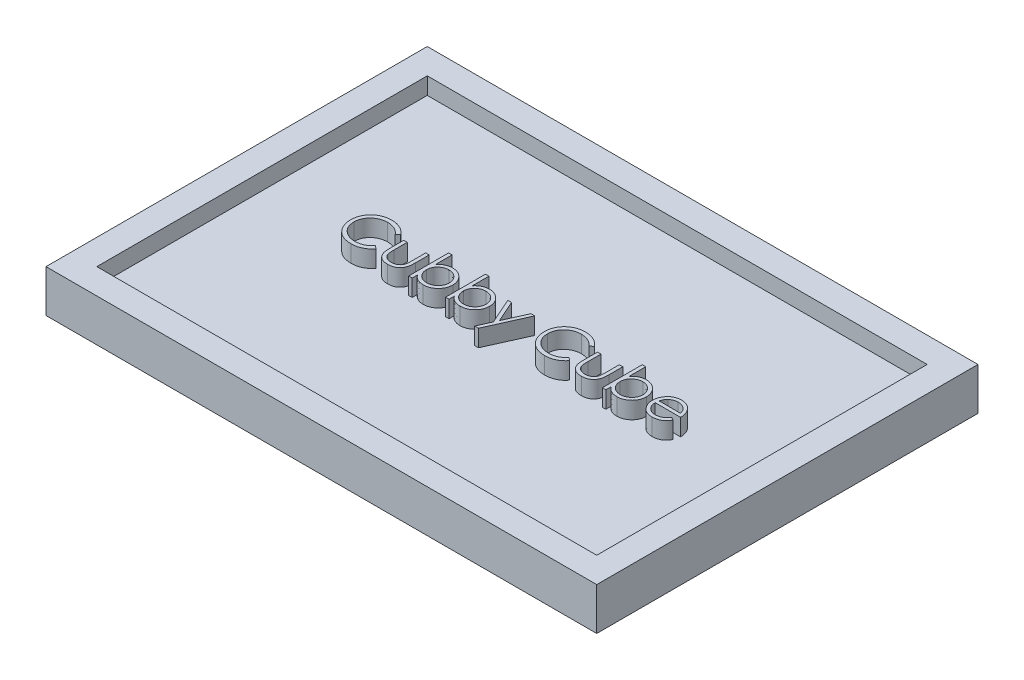
from build123d import *

# Parameters (mm, degrees)
SKETCH1_W           = 82.55
SKETCH1_H           = 57.15
BOSS_EXTRUDE1_DEPTH = 6.35
SHELL1_T            = -3.81
BOSS_EXTRUDE2_DEPTH = 2.54


with BuildPart() as part:
    # Sketch1 → Boss-Extrude1 (new body)
    with BuildSketch(Plane(origin=(0, 0, 0), x_dir=(1, 0, 0), z_dir=(0, 1, 0))):
        with Locations((41.275, 28.575)):
            Rectangle(SKETCH1_W, SKETCH1_H)
    extrude(amount=BOSS_EXTRUDE1_DEPTH)

    # Shell1
    shell1_openings = [part.faces().sort_by_distance(p)[0] for p in [
        (41.275, 6.35, -28.575),
    ]]
    offset(amount=SHELL1_T, openings=shell1_openings, kind=Kind.INTERSECTION)

    # Sketch2 → Boss-Extrude2 (add)
    with BuildSketch(Plane(origin=(0, 3.81, 0), x_dir=(1, 0, 0), z_dir=(0, 1, 0))):
        with BuildLine():
            Line((22.421777935, 30.73376706), (21.964693267, 30.383957364))
            add(Edge.make_bspline(
                [(21.964693267, 30.383957364), (21.932086807, 30.422817197), (21.867313494, 30.500012949), (21.763105272, 30.608412739), (21.654502421, 30.709970084), (21.541546454, 30.805168782), (21.422204204, 30.89067976), (21.299366661, 30.970959201), (21.17097896, 31.04291757), (20.993440658, 31.130168513), (20.761192987, 31.221216582), (20.468829427, 31.297558028), (20.163632993, 31.346155626), (19.955417461, 31.351419059), (19.849510641, 31.354096253)],
                knots=[0, 0, 0, 0, 0.000152148, 0.000302245, 0.000450739, 0.000598094, 0.000745032, 0.000890898, 0.001038133, 0.001186232, 0.001484183, 0.001784551, 0.002091286, 0.002408809, 0.002408809, 0.002408809, 0.002408809], degree=3))
            add(Edge.make_bspline(
                [(19.849510641, 31.354096253), (19.791163773, 31.353424425), (19.675011551, 31.352087004), (19.502634268, 31.334443018), (19.333475777, 31.309644256), (19.167646112, 31.272847736), (19.005356359, 31.226326606), (18.845545542, 31.17073696), (18.690527438, 31.101959923), (18.538157582, 31.025942733), (18.392172394, 30.940081376), (18.25404394, 30.846426908), (18.124275998, 30.746027351), (18.002765916, 30.638506404), (17.889389473, 30.524348287), (17.784968195, 30.402336399), (17.689863412, 30.27286082), (17.602189978, 30.13762888), (17.523670706, 29.997034481), (17.457928752, 29.850557251), (17.3997119, 29.700705546), (17.353645422, 29.545786294), (17.317182862, 29.386889575), (17.292024117, 29.223588943), (17.274580791, 29.05622555), (17.273250021, 28.942786967), (17.272579217, 28.885605835)],
                knots=[0, 0, 0, 0, 0.000174967, 0.00034831, 0.00051932, 0.000687657, 0.000857434, 0.001025602, 0.001194789, 0.00136583, 0.001536215, 0.001702447, 0.001866178, 0.002028084, 0.002188866, 0.002348476, 0.002509393, 0.002670461, 0.002831737, 0.002991929, 0.003151744, 0.003313688, 0.003476336, 0.003640432, 0.003809132, 0.003980603, 0.003980603, 0.003980603, 0.003980603], degree=3))
            add(Edge.make_bspline(
                [(17.272579217, 28.885605835), (17.274677743, 28.799571723), (17.278797918, 28.630655156), (17.315466398, 28.383235462), (17.371188556, 28.146210009), (17.454701843, 27.921060438), (17.557679121, 27.705010466), (17.687800709, 27.501715611), (17.838504641, 27.308103777), (18.011922931, 27.128750684), (18.202190699, 26.964912976), (18.406332166, 26.820638497), (18.623838893, 26.700371961), (18.852309312, 26.600293631), (19.093501552, 26.523364287), (19.346981884, 26.469207048), (19.612199, 26.433879279), (19.79342549, 26.430497062), (19.885657643, 26.42877574)],
                knots=[0, 0, 0, 0, 0.000257957, 0.000506464, 0.000748833, 0.000987126, 0.001225457, 0.00146549, 0.001709706, 0.001960405, 0.002212595, 0.002462011, 0.002708907, 0.002956946, 0.003209176, 0.003466933, 0.003733773, 0.004010322, 0.004010322, 0.004010322, 0.004010322], degree=3))
            add(Edge.make_bspline(
                [(19.885657643, 26.42877574), (19.987277234, 26.431584342), (20.187288899, 26.437112341), (20.480605723, 26.483943855), (20.761395681, 26.55987732), (21.029673876, 26.666145651), (21.284683996, 26.804291135), (21.526825108, 26.971761296), (21.756301601, 27.170149154), (21.894290745, 27.321629071), (21.964693267, 27.398914629)],
                knots=[0, 0, 0, 0, 0.000304712, 0.000599746, 0.00088855, 0.001175882, 0.001463346, 0.001756709, 0.002057595, 0.002371017, 0.002371017, 0.002371017, 0.002371017], degree=3))
            Line((21.964693267, 27.398914629), (22.421777935, 27.05260303))
            add(Edge.make_bspline(
                [(22.421777935, 27.05260303), (22.384993412, 27.005140867), (22.311600561, 26.910443881), (22.192759074, 26.776944383), (22.067565759, 26.651373981), (21.935090727, 26.534745068), (21.796857923, 26.424723891), (21.65038528, 26.324436203), (21.49759833, 26.232482197), (21.33901475, 26.148284799), (21.174803033, 26.07358314), (21.005159943, 26.009630862), (20.830816712, 25.954541016), (20.65176537, 25.909218449), (20.467634522, 25.873842611), (20.279088627, 25.850193938), (20.085720751, 25.833992206), (19.955265197, 25.832515518), (19.88915574, 25.831767193)],
                knots=[0, 0, 0, 0, 0.000180102, 0.000359341, 0.000535786, 0.000711734, 0.00088856, 0.001065478, 0.001243854, 0.001423287, 0.001603841, 0.00178467, 0.001966848, 0.002152085, 0.002338465, 0.002528942, 0.002721934, 0.002920214, 0.002920214, 0.002920214, 0.002920214], degree=3))
            add(Edge.make_bspline(
                [(19.88915574, 25.831767193), (19.826550736, 25.832202912), (19.702757095, 25.833064491), (19.519985004, 25.847021465), (19.342051142, 25.866063468), (19.169464056, 25.894735448), (19.001281928, 25.928570023), (18.839029385, 25.97392472), (18.681109826, 26.024730893), (18.528157717, 26.084444306), (18.380042954, 26.151826576), (18.237243259, 26.2279823), (18.099824306, 26.312271067), (17.966435053, 26.402834936), (17.839045976, 26.502582901), (17.716553149, 26.610129673), (17.598269697, 26.725112769), (17.525089041, 26.808026139), (17.488295196, 26.849713407)],
                knots=[0, 0, 0, 0, 0.000187764, 0.00037128, 0.000549622, 0.000724449, 0.000895963, 0.001063989, 0.001229553, 0.001393471, 0.001556269, 0.001717456, 0.001878638, 0.002039703, 0.002200877, 0.002363659, 0.002528569, 0.002695324, 0.002695324, 0.002695324, 0.002695324], degree=3))
            add(Edge.make_bspline(
                [(17.488295196, 26.849713407), (17.429362346, 26.922126551), (17.312208135, 27.066078604), (17.16232054, 27.299387551), (17.034016809, 27.542978132), (16.930279712, 27.798130085), (16.849182642, 28.064270871), (16.793001298, 28.341534649), (16.756493689, 28.629662477), (16.75231884, 28.825636279), (16.750196739, 28.925250934)],
                knots=[0, 0, 0, 0, 0.000279908, 0.000556438, 0.000830257, 0.00110482, 0.001381467, 0.001663661, 0.00195263, 0.002251362, 0.002251362, 0.002251362, 0.002251362], degree=3))
            add(Edge.make_bspline(
                [(16.750196739, 28.925250934), (16.752783174, 29.029951849), (16.757871823, 29.235944363), (16.801105307, 29.538251759), (16.870653948, 29.827882121), (16.96943663, 30.104294777), (17.094676601, 30.368943588), (17.24938872, 30.619806878), (17.431775622, 30.858488984), (17.640406874, 31.081368279), (17.869194455, 31.285162892), (18.114199672, 31.464454877), (18.374942982, 31.61366365), (18.648551838, 31.738389411), (18.937075048, 31.834257643), (19.239897033, 31.901368836), (19.556448775, 31.943140992), (19.772422357, 31.948421665), (19.882159546, 31.9511048)],
                knots=[0, 0, 0, 0, 0.000313975, 0.000617725, 0.000914111, 0.001206206, 0.001496719, 0.001790895, 0.00208871, 0.002396439, 0.002705339, 0.003006674, 0.003305479, 0.00360502, 0.00390738, 0.004215724, 0.004534343, 0.004863462, 0.004863462, 0.004863462, 0.004863462], degree=3))
            add(Edge.make_bspline(
                [(19.882159546, 31.9511048), (19.949040043, 31.950302958), (20.081423251, 31.948715793), (20.277257126, 31.933238793), (20.467918234, 31.907438188), (20.653537927, 31.872320153), (20.83501923, 31.828734881), (21.010975107, 31.771956314), (21.182438042, 31.707034844), (21.34832665, 31.632264634), (21.507845008, 31.548333636), (21.660943433, 31.456172177), (21.806405823, 31.35589451), (21.945255729, 31.248353491), (22.075170428, 31.131273982), (22.199838506, 31.007876313), (22.315026275, 30.874606132), (22.38612891, 30.780799355), (22.421777935, 30.73376706)],
                knots=[0, 0, 0, 0, 0.000200612, 0.000397091, 0.000588877, 0.000777548, 0.000963635, 0.001148388, 0.001331811, 0.001513428, 0.001693892, 0.001872268, 0.002049186, 0.002223655, 0.002398731, 0.002573527, 0.002749582, 0.002926608, 0.002926608, 0.002926608, 0.002926608], degree=3))
        make_face()
        with BuildLine():
            Line((23.391916824, 30.234705227), (23.914299303, 30.234705227))
            Line((23.914299303, 30.234705227), (23.914299303, 28.261778545))
            add(Edge.make_bspline(
                [(23.914299303, 28.261778545), (23.914535304, 28.203864996), (23.914986764, 28.093079091), (23.918048424, 27.933662786), (23.925249782, 27.788280468), (23.934253488, 27.656848152), (23.945832183, 27.539388073), (23.959608201, 27.4363105), (23.975005837, 27.346446506), (23.990077994, 27.292323806), (23.997087597, 27.267152977)],
                knots=[0, 0, 0, 0, 0.000173743, 0.000332362, 0.000478284, 0.000610375, 0.00072756, 0.000832276, 0.000922385, 0.001000727, 0.001000727, 0.001000727, 0.001000727], degree=3))
            add(Edge.make_bspline(
                [(23.997087597, 27.267152977), (24.008332541, 27.235516131), (24.030588649, 27.172900161), (24.070957764, 27.082446065), (24.120897748, 26.998667173), (24.175546771, 26.9183329), (24.238577095, 26.843822929), (24.309191239, 26.775263085), (24.38502545, 26.710062948), (24.497708507, 26.632920621), (24.651809691, 26.550239293), (24.854129809, 26.478899461), (25.073499099, 26.436264651), (25.225114709, 26.431318182), (25.303043794, 26.42877574)],
                knots=[0, 0, 0, 0, 0.000100718, 0.000199343, 0.000296537, 0.000392924, 0.000490565, 0.000588685, 0.000687969, 0.000790181, 0.000997804, 0.001210601, 0.001431508, 0.001665134, 0.001665134, 0.001665134, 0.001665134], degree=3))
            add(Edge.make_bspline(
                [(25.303043794, 26.42877574), (25.38096564, 26.431372245), (25.531729993, 26.436396002), (25.748689031, 26.477613387), (25.947015491, 26.546474992), (26.124718799, 26.642614223), (26.28099294, 26.760265011), (26.411220646, 26.898316565), (26.518668664, 27.052401319), (26.565583617, 27.167361578), (26.589177441, 27.225175814)],
                knots=[0, 0, 0, 0, 0.000233626, 0.000452023, 0.000659645, 0.000861028, 0.001055759, 0.001243812, 0.00142848, 0.001615308, 0.001615308, 0.001615308, 0.001615308], degree=3))
            add(Edge.make_bspline(
                [(26.589177441, 27.225175814), (26.596152845, 27.248403098), (26.61157376, 27.299752952), (26.628142099, 27.386865462), (26.643067484, 27.490750049), (26.655812075, 27.612086498), (26.664901161, 27.750557724), (26.669800684, 27.906120453), (26.675335923, 28.078286335), (26.675419936, 28.19880712), (26.675463833, 28.261778545)],
                knots=[0, 0, 0, 0, 7.2716e-05, 0.000160757, 0.000265635, 0.000387579, 0.00052665, 0.000681842, 0.000854478, 0.001043379, 0.001043379, 0.001043379, 0.001043379], degree=3))
            Line((26.675463833, 28.261778545), (26.675463833, 30.234705227))
            Line((26.675463833, 30.234705227), (27.197846311, 30.234705227))
            Line((27.197846311, 30.234705227), (27.197846311, 28.16383183))
            add(Edge.make_bspline(
                [(27.197846311, 28.16383183), (27.197111731, 28.093470975), (27.195686544, 27.95696129), (27.186527307, 27.758580452), (27.170811702, 27.573707052), (27.14695845, 27.402243231), (27.118909227, 27.244319895), (27.082726473, 27.099734643), (27.03952219, 26.968932944), (26.990784327, 26.849619536), (26.933204864, 26.741440356), (26.871958022, 26.638767814), (26.801235276, 26.544149444), (26.726778113, 26.452875223), (26.643953216, 26.369485088), (26.554312618, 26.29206555), (26.459118011, 26.219433139), (26.356256904, 26.154420618), (26.247230928, 26.095851983), (26.13190549, 26.043936672), (26.008868044, 26.002853934), (25.879706019, 25.967412267), (25.743786602, 25.939614513), (25.601240824, 25.92001233), (25.452116702, 25.907995917), (25.35048585, 25.90693645), (25.298379665, 25.906393262)],
                knots=[0, 0, 0, 0, 0.000211081, 0.000409526, 0.000595642, 0.000767473, 0.00092871, 0.001076617, 0.001214155, 0.001341701, 0.001462699, 0.001581485, 0.001699962, 0.001816711, 0.001934619, 0.002051989, 0.002171858, 0.002293484, 0.002416604, 0.002542929, 0.002672358, 0.002805307, 0.002944573, 0.003088203, 0.003236748, 0.003393035, 0.003393035, 0.003393035, 0.003393035], degree=3))
            add(Edge.make_bspline(
                [(25.298379665, 25.906393262), (25.2466632, 25.906958227), (25.145035533, 25.908068436), (24.995903714, 25.919945943), (24.852962996, 25.939584055), (24.716721571, 25.967615887), (24.587042722, 26.002605864), (24.463401171, 26.044189125), (24.347244674, 26.095878926), (24.237177698, 26.154049935), (24.134061822, 26.219850756), (24.037421722, 26.291975936), (23.94738698, 26.370317806), (23.863937738, 26.454549184), (23.788245323, 26.54571497), (23.719366501, 26.643081812), (23.656240886, 26.745684957), (23.599108924, 26.855554288), (23.550028064, 26.976248452), (23.506695708, 27.109790172), (23.471254087, 27.257643524), (23.44241191, 27.419682101), (23.419209336, 27.595130402), (23.403100359, 27.78500335), (23.394093317, 27.988838443), (23.392657963, 28.129619272), (23.391916824, 28.202310896)],
                knots=[0, 0, 0, 0, 0.000155122, 0.000304829, 0.000448459, 0.000587725, 0.000721799, 0.000851229, 0.00097862, 0.001102768, 0.001224394, 0.001345195, 0.00146421, 0.001582118, 0.001700509, 0.00181925, 0.001939639, 0.002061672, 0.002190296, 0.00233005, 0.002482483, 0.002646015, 0.002823624, 0.003013225, 0.003217494, 0.00343557, 0.00343557, 0.00343557, 0.00343557], degree=3))
            Line((23.391916824, 28.202310896), (23.391916824, 30.234705227))
        make_face()
        with BuildLine():
            Line((28.391863405, 25.98101933), (28.391863405, 31.9511048))
            Line((28.391863405, 31.9511048), (28.914245884, 31.9511048))
            Line((28.914245884, 31.9511048), (28.914245884, 29.462791833))
            add(Edge.make_bspline(
                [(28.914245884, 29.462791833), (28.973108511, 29.530576155), (29.087951922, 29.662826162), (29.280499186, 29.835534694), (29.482408211, 29.98197435), (29.695214977, 30.102691978), (29.919222153, 30.194617251), (30.153273052, 30.261843535), (30.397965986, 30.302401277), (30.564806326, 30.30700152), (30.649301974, 30.309331296)],
                knots=[0, 0, 0, 0, 0.000269114, 0.000525052, 0.000773922, 0.00101618, 0.00125719, 0.001498562, 0.001745466, 0.00199882, 0.00199882, 0.00199882, 0.00199882], degree=3))
            add(Edge.make_bspline(
                [(30.649301974, 30.309331296), (30.724417562, 30.307268678), (30.872933883, 30.303190532), (31.091268597, 30.272199591), (31.301339603, 30.221944509), (31.503032556, 30.152273825), (31.695406328, 30.05983404), (31.880108117, 29.949169508), (32.056191626, 29.81738862), (32.220929334, 29.666715001), (32.372759762, 29.50313857), (32.505661877, 29.328213688), (32.6179203, 29.144483091), (32.710773057, 28.952561797), (32.78257063, 28.751665961), (32.832034853, 28.541992562), (32.863456483, 28.323747869), (32.867415059, 28.17521217), (32.869427508, 28.099700052)],
                knots=[0, 0, 0, 0, 0.000225289, 0.000445434, 0.000660092, 0.000872502, 0.001084258, 0.001299229, 0.001517511, 0.001742857, 0.001968131, 0.002186182, 0.00240076, 0.00261302, 0.002824718, 0.003039376, 0.003258366, 0.00348482, 0.00348482, 0.00348482, 0.00348482], degree=3))
            add(Edge.make_bspline(
                [(32.869427508, 28.099700052), (32.86737119, 28.025359666), (32.863316454, 27.878772131), (32.832347445, 27.663057775), (32.781213479, 27.455439129), (32.708101844, 27.256452682), (32.616190987, 27.065163612), (32.501252354, 26.883752511), (32.368519061, 26.709062691), (32.214963567, 26.546705294), (32.048797813, 26.396638556), (31.870989245, 26.266242135), (31.686016597, 26.153622116), (31.490996873, 26.064387996), (31.288817643, 25.99220813), (31.077312862, 25.942119542), (30.857679137, 25.912893878), (30.708468081, 25.908577203), (30.632977521, 25.906393262)],
                knots=[0, 0, 0, 0, 0.000222959, 0.000439641, 0.00065231, 0.000863307, 0.001074516, 0.001287725, 0.001506483, 0.001731696, 0.001957127, 0.002177281, 0.002392252, 0.002605624, 0.00281952, 0.003035311, 0.003256455, 0.003482909, 0.003482909, 0.003482909, 0.003482909], degree=3))
            add(Edge.make_bspline(
                [(30.632977521, 25.906393262), (30.546554591, 25.90878913), (30.377094292, 25.913487011), (30.129205515, 25.952435004), (29.894573461, 26.018728658), (29.670525348, 26.107806959), (29.460264004, 26.228429018), (29.262454488, 26.378035661), (29.078344236, 26.559092077), (28.969882461, 26.697231246), (28.914245884, 26.768091145)],
                knots=[0, 0, 0, 0, 0.000259177, 0.0005082, 0.000750376, 0.000989424, 0.001229652, 0.00147522, 0.001731655, 0.002001737, 0.002001737, 0.002001737, 0.002001737], degree=3))
            Line((28.914245884, 26.768091145), (28.914245884, 25.98101933))
            Line((28.914245884, 25.98101933), (28.391863405, 25.98101933))
        make_face()
        with BuildLine():
            add(Edge.make_bspline(
                [(30.628313392, 26.42877574), (30.704673333, 26.431492621), (30.855395711, 26.43685531), (31.076660205, 26.478721443), (31.288395861, 26.548378713), (31.489535725, 26.643646976), (31.676932152, 26.763426479), (31.844327069, 26.90835886), (31.993140347, 27.073839355), (32.117293361, 27.260494676), (32.220947841, 27.459153014), (32.292150397, 27.668128085), (32.339914028, 27.881827156), (32.344657672, 28.026759328), (32.347045029, 28.099700052)],
                knots=[0, 0, 0, 0, 0.00022897, 0.000451951, 0.000672824, 0.000896061, 0.001117941, 0.001337879, 0.001558371, 0.00178346, 0.002008743, 0.002228527, 0.00244418, 0.002662676, 0.002662676, 0.002662676, 0.002662676], degree=3))
            add(Edge.make_bspline(
                [(32.347045029, 28.099700052), (32.343905531, 28.172569472), (32.337639069, 28.318017396), (32.293775294, 28.53363714), (32.217176803, 28.742501321), (32.11553171, 28.944031857), (31.989356025, 29.131974591), (31.84133063, 29.300762338), (31.671891484, 29.446382931), (31.484255392, 29.567772371), (31.284384289, 29.66682558), (31.074018319, 29.734754747), (30.857552965, 29.779222899), (30.710542842, 29.784360414), (30.636475618, 29.786948817)],
                knots=[0, 0, 0, 0, 0.000218574, 0.000436276, 0.000656838, 0.000884199, 0.001111874, 0.00133411, 0.001555693, 0.00177982, 0.002003017, 0.002222782, 0.0024414, 0.002663388, 0.002663388, 0.002663388, 0.002663388], degree=3))
            add(Edge.make_bspline(
                [(30.636475618, 29.786948817), (30.560858823, 29.784361877), (30.410774828, 29.779227325), (30.189303392, 29.734676622), (29.972995764, 29.666410535), (29.766293762, 29.568402089), (29.573617434, 29.448473862), (29.401299792, 29.30754284), (29.252732904, 29.146588636), (29.130422609, 28.966133153), (29.033289866, 28.771243279), (28.963799513, 28.563336079), (28.92222272, 28.343505968), (28.916937183, 28.192774315), (28.914245884, 28.116024505)],
                knots=[0, 0, 0, 0, 0.000226643, 0.00044984, 0.00067515, 0.000905709, 0.00113412, 0.001354485, 0.00157152, 0.001788856, 0.002006308, 0.002222754, 0.002444588, 0.002674722, 0.002674722, 0.002674722, 0.002674722], degree=3))
            add(Edge.make_bspline(
                [(28.914245884, 28.116024505), (28.915841907, 28.057254347), (28.918983386, 27.941576079), (28.942982464, 27.771728003), (28.981159915, 27.609188563), (29.034950226, 27.453780636), (29.105633827, 27.306386426), (29.190801376, 27.165861398), (29.292169769, 27.033473564), (29.40676799, 26.90954749), (29.533100664, 26.796773976), (29.668681374, 26.69902019), (29.810739528, 26.614843971), (29.960900349, 26.547746656), (30.117416388, 26.492986716), (30.281893748, 26.456841427), (30.452646105, 26.431936511), (30.569141099, 26.429840424), (30.628313392, 26.42877574)],
                knots=[0, 0, 0, 0, 0.00017626, 0.000346935, 0.000513519, 0.000676513, 0.000839241, 0.001003022, 0.001168602, 0.001338579, 0.001508716, 0.001675715, 0.001839301, 0.002003161, 0.002168359, 0.002335814, 0.002507644, 0.002685019, 0.002685019, 0.002685019, 0.002685019], degree=3))
        make_face(mode=Mode.SUBTRACT)
        with BuildLine():
            Line((33.914192465, 25.98101933), (33.914192465, 31.9511048))
            Line((33.914192465, 31.9511048), (34.436574944, 31.9511048))
            Line((34.436574944, 31.9511048), (34.436574944, 29.462791833))
            add(Edge.make_bspline(
                [(34.436574944, 29.462791833), (34.49543757, 29.530576155), (34.610280981, 29.662826162), (34.802828246, 29.835534694), (35.004737271, 29.98197435), (35.217544037, 30.102691978), (35.441551212, 30.194617251), (35.675602112, 30.261843535), (35.920295045, 30.302401277), (36.087135386, 30.30700152), (36.171631034, 30.309331296)],
                knots=[0, 0, 0, 0, 0.000269114, 0.000525052, 0.000773922, 0.00101618, 0.00125719, 0.001498562, 0.001745466, 0.00199882, 0.00199882, 0.00199882, 0.00199882], degree=3))
            add(Edge.make_bspline(
                [(36.171631034, 30.309331296), (36.246746622, 30.307268678), (36.395262943, 30.303190532), (36.613597657, 30.272199591), (36.823668663, 30.221944509), (37.025361615, 30.152273825), (37.217735388, 30.05983404), (37.402437177, 29.949169508), (37.578520686, 29.81738862), (37.743258394, 29.666715001), (37.895088822, 29.50313857), (38.027990937, 29.328213688), (38.14024936, 29.144483091), (38.233102117, 28.952561797), (38.304899689, 28.751665961), (38.354363912, 28.541992562), (38.385785543, 28.323747869), (38.389744119, 28.17521217), (38.391756568, 28.099700052)],
                knots=[0, 0, 0, 0, 0.000225289, 0.000445434, 0.000660092, 0.000872502, 0.001084258, 0.001299229, 0.001517511, 0.001742857, 0.001968131, 0.002186182, 0.00240076, 0.00261302, 0.002824718, 0.003039376, 0.003258366, 0.00348482, 0.00348482, 0.00348482, 0.00348482], degree=3))
            add(Edge.make_bspline(
                [(38.391756568, 28.099700052), (38.389700249, 28.025359666), (38.385645514, 27.878772131), (38.354676505, 27.663057775), (38.303542538, 27.455439129), (38.230430904, 27.256452682), (38.138520047, 27.065163612), (38.023581414, 26.883752511), (37.890848121, 26.709062691), (37.737292627, 26.546705294), (37.571126873, 26.396638556), (37.393318305, 26.266242135), (37.208345657, 26.153622116), (37.013325933, 26.064387996), (36.811146703, 25.99220813), (36.599641922, 25.942119542), (36.380008196, 25.912893878), (36.23079714, 25.908577203), (36.155306581, 25.906393262)],
                knots=[0, 0, 0, 0, 0.000222959, 0.000439641, 0.00065231, 0.000863307, 0.001074516, 0.001287725, 0.001506483, 0.001731696, 0.001957127, 0.002177281, 0.002392252, 0.002605624, 0.00281952, 0.003035311, 0.003256455, 0.003482909, 0.003482909, 0.003482909, 0.003482909], degree=3))
            add(Edge.make_bspline(
                [(36.155306581, 25.906393262), (36.06888365, 25.90878913), (35.899423352, 25.913487011), (35.651534574, 25.952435004), (35.416902521, 26.018728658), (35.192854408, 26.107806959), (34.982593064, 26.228429018), (34.784783548, 26.378035661), (34.600673296, 26.559092077), (34.492211521, 26.697231246), (34.436574944, 26.768091145)],
                knots=[0, 0, 0, 0, 0.000259177, 0.0005082, 0.000750376, 0.000989424, 0.001229652, 0.00147522, 0.001731655, 0.002001737, 0.002001737, 0.002001737, 0.002001737], degree=3))
            Line((34.436574944, 26.768091145), (34.436574944, 25.98101933))
            Line((34.436574944, 25.98101933), (33.914192465, 25.98101933))
        make_face()
        with BuildLine():
            add(Edge.make_bspline(
                [(36.150642452, 26.42877574), (36.227002393, 26.431492621), (36.377724771, 26.43685531), (36.598989265, 26.478721443), (36.810724921, 26.548378713), (37.011864785, 26.643646976), (37.199261212, 26.763426479), (37.366656128, 26.90835886), (37.515469407, 27.073839355), (37.63962242, 27.260494676), (37.743276901, 27.459153014), (37.814479457, 27.668128085), (37.862243088, 27.881827156), (37.866986732, 28.026759328), (37.869374089, 28.099700052)],
                knots=[0, 0, 0, 0, 0.00022897, 0.000451951, 0.000672824, 0.000896061, 0.001117941, 0.001337879, 0.001558371, 0.00178346, 0.002008743, 0.002228527, 0.00244418, 0.002662676, 0.002662676, 0.002662676, 0.002662676], degree=3))
            add(Edge.make_bspline(
                [(37.869374089, 28.099700052), (37.866234591, 28.172569472), (37.859968129, 28.318017396), (37.816104354, 28.53363714), (37.739505863, 28.742501321), (37.637860769, 28.944031857), (37.511685084, 29.131974591), (37.36365969, 29.300762338), (37.194220544, 29.446382931), (37.006584452, 29.567772371), (36.806713349, 29.66682558), (36.596347379, 29.734754747), (36.379882025, 29.779222899), (36.232871902, 29.784360414), (36.158804678, 29.786948817)],
                knots=[0, 0, 0, 0, 0.000218574, 0.000436276, 0.000656838, 0.000884199, 0.001111874, 0.00133411, 0.001555693, 0.00177982, 0.002003017, 0.002222782, 0.0024414, 0.002663388, 0.002663388, 0.002663388, 0.002663388], degree=3))
            add(Edge.make_bspline(
                [(36.158804678, 29.786948817), (36.083187883, 29.784361877), (35.933103888, 29.779227325), (35.711632452, 29.734676622), (35.495324824, 29.666410535), (35.288622821, 29.568402089), (35.095946494, 29.448473862), (34.923628851, 29.30754284), (34.775061963, 29.146588636), (34.652751668, 28.966133153), (34.555618925, 28.771243279), (34.486128573, 28.563336079), (34.44455178, 28.343505968), (34.439266243, 28.192774315), (34.436574944, 28.116024505)],
                knots=[0, 0, 0, 0, 0.000226643, 0.00044984, 0.00067515, 0.000905709, 0.00113412, 0.001354485, 0.00157152, 0.001788856, 0.002006308, 0.002222754, 0.002444588, 0.002674722, 0.002674722, 0.002674722, 0.002674722], degree=3))
            add(Edge.make_bspline(
                [(34.436574944, 28.116024505), (34.438170967, 28.057254347), (34.441312446, 27.941576079), (34.465311524, 27.771728003), (34.503488975, 27.609188563), (34.557279286, 27.453780636), (34.627962887, 27.306386426), (34.713130436, 27.165861398), (34.814498829, 27.033473564), (34.92909705, 26.90954749), (35.055429724, 26.796773976), (35.191010434, 26.69902019), (35.333068588, 26.614843971), (35.483229409, 26.547746656), (35.639745448, 26.492986716), (35.804222808, 26.456841427), (35.974975165, 26.431936511), (36.091470158, 26.429840424), (36.150642452, 26.42877574)],
                knots=[0, 0, 0, 0, 0.00017626, 0.000346935, 0.000513519, 0.000676513, 0.000839241, 0.001003022, 0.001168602, 0.001338579, 0.001508716, 0.001675715, 0.001839301, 0.002003161, 0.002168359, 0.002335814, 0.002507644, 0.002685019, 0.002685019, 0.002685019, 0.002685019], degree=3))
        make_face(mode=Mode.SUBTRACT)
        Polygon((38.988765115, 30.234705227), (39.551958725, 30.234705227), (40.992008638, 26.97681093), (42.454213165, 30.234705227), (43.018572807, 30.234705227), (40.406660414, 24.413871894), (39.842300772, 24.413871894), (40.708662784, 26.343655381), align=None)
        with BuildLine():
            Line((51.451318534, 30.73376706), (50.994233865, 30.383957364))
            add(Edge.make_bspline(
                [(50.994233865, 30.383957364), (50.961627405, 30.422817197), (50.896854092, 30.500012949), (50.792645871, 30.608412739), (50.684043019, 30.709970084), (50.571087052, 30.805168782), (50.451744802, 30.89067976), (50.32890726, 30.970959201), (50.200519558, 31.04291757), (50.022981257, 31.130168513), (49.790733585, 31.221216582), (49.498370026, 31.297558028), (49.193173592, 31.346155626), (48.98495806, 31.351419059), (48.879051239, 31.354096253)],
                knots=[0, 0, 0, 0, 0.000152148, 0.000302245, 0.000450739, 0.000598094, 0.000745032, 0.000890898, 0.001038133, 0.001186232, 0.001484183, 0.001784551, 0.002091286, 0.002408809, 0.002408809, 0.002408809, 0.002408809], degree=3))
            add(Edge.make_bspline(
                [(48.879051239, 31.354096253), (48.820704371, 31.353424425), (48.704552149, 31.352087004), (48.532174866, 31.334443018), (48.363016375, 31.309644256), (48.197186711, 31.272847736), (48.034896957, 31.226326606), (47.875086141, 31.17073696), (47.720068036, 31.101959923), (47.56769818, 31.025942733), (47.421712993, 30.940081376), (47.283584538, 30.846426908), (47.153816596, 30.746027351), (47.032306514, 30.638506404), (46.918930071, 30.524348287), (46.814508794, 30.402336399), (46.71940401, 30.27286082), (46.631730577, 30.13762888), (46.553211305, 29.997034481), (46.487469351, 29.850557251), (46.429252499, 29.700705546), (46.38318602, 29.545786294), (46.34672346, 29.386889575), (46.321564716, 29.223588943), (46.304121389, 29.05622555), (46.302790619, 28.942786967), (46.302119816, 28.885605835)],
                knots=[0, 0, 0, 0, 0.000174967, 0.00034831, 0.00051932, 0.000687657, 0.000857434, 0.001025602, 0.001194789, 0.00136583, 0.001536215, 0.001702447, 0.001866178, 0.002028084, 0.002188866, 0.002348476, 0.002509393, 0.002670461, 0.002831737, 0.002991929, 0.003151744, 0.003313688, 0.003476336, 0.003640432, 0.003809132, 0.003980603, 0.003980603, 0.003980603, 0.003980603], degree=3))
            add(Edge.make_bspline(
                [(46.302119816, 28.885605835), (46.304218341, 28.799571723), (46.308338517, 28.630655156), (46.345006996, 28.383235462), (46.400729154, 28.146210009), (46.484242441, 27.921060438), (46.587219719, 27.705010466), (46.717341307, 27.501715611), (46.868045239, 27.308103777), (47.04146353, 27.128750684), (47.231731297, 26.964912976), (47.435872765, 26.820638497), (47.653379491, 26.700371961), (47.88184991, 26.600293631), (48.12304215, 26.523364287), (48.376522482, 26.469207048), (48.641739598, 26.433879279), (48.822966088, 26.430497062), (48.915198241, 26.42877574)],
                knots=[0, 0, 0, 0, 0.000257957, 0.000506464, 0.000748833, 0.000987126, 0.001225457, 0.00146549, 0.001709706, 0.001960405, 0.002212595, 0.002462011, 0.002708907, 0.002956946, 0.003209176, 0.003466933, 0.003733773, 0.004010322, 0.004010322, 0.004010322, 0.004010322], degree=3))
            add(Edge.make_bspline(
                [(48.915198241, 26.42877574), (49.016817832, 26.431584342), (49.216829497, 26.437112341), (49.510146322, 26.483943855), (49.79093628, 26.55987732), (50.059214474, 26.666145651), (50.314224594, 26.804291135), (50.556365706, 26.971761296), (50.785842199, 27.170149154), (50.923831344, 27.321629071), (50.994233865, 27.398914629)],
                knots=[0, 0, 0, 0, 0.000304712, 0.000599746, 0.00088855, 0.001175882, 0.001463346, 0.001756709, 0.002057595, 0.002371017, 0.002371017, 0.002371017, 0.002371017], degree=3))
            Line((50.994233865, 27.398914629), (51.451318534, 27.05260303))
            add(Edge.make_bspline(
                [(51.451318534, 27.05260303), (51.41453401, 27.005140867), (51.34114116, 26.910443881), (51.222299672, 26.776944383), (51.097106357, 26.651373981), (50.964631325, 26.534745068), (50.826398522, 26.424723891), (50.679925878, 26.324436203), (50.527138928, 26.232482197), (50.368555348, 26.148284799), (50.204343631, 26.07358314), (50.034700541, 26.009630862), (49.86035731, 25.954541016), (49.681305969, 25.909218449), (49.497175121, 25.873842611), (49.308629225, 25.850193938), (49.115261349, 25.833992206), (48.984805795, 25.832515518), (48.918696338, 25.831767193)],
                knots=[0, 0, 0, 0, 0.000180102, 0.000359341, 0.000535786, 0.000711734, 0.00088856, 0.001065478, 0.001243854, 0.001423287, 0.001603841, 0.00178467, 0.001966848, 0.002152085, 0.002338465, 0.002528942, 0.002721934, 0.002920214, 0.002920214, 0.002920214, 0.002920214], degree=3))
            add(Edge.make_bspline(
                [(48.918696338, 25.831767193), (48.856091335, 25.832202912), (48.732297693, 25.833064491), (48.549525602, 25.847021465), (48.37159174, 25.866063468), (48.199004654, 25.894735448), (48.030822526, 25.928570023), (47.868569983, 25.97392472), (47.710650425, 26.024730893), (47.557698315, 26.084444306), (47.409583553, 26.151826576), (47.266783857, 26.2279823), (47.129364904, 26.312271067), (46.995975651, 26.402834936), (46.868586574, 26.502582901), (46.746093747, 26.610129673), (46.627810295, 26.725112769), (46.55462964, 26.808026139), (46.517835795, 26.849713407)],
                knots=[0, 0, 0, 0, 0.000187764, 0.00037128, 0.000549622, 0.000724449, 0.000895963, 0.001063989, 0.001229553, 0.001393471, 0.001556269, 0.001717456, 0.001878638, 0.002039703, 0.002200877, 0.002363659, 0.002528569, 0.002695324, 0.002695324, 0.002695324, 0.002695324], degree=3))
            add(Edge.make_bspline(
                [(46.517835795, 26.849713407), (46.458902945, 26.922126551), (46.341748734, 27.066078604), (46.191861139, 27.299387551), (46.063557407, 27.542978132), (45.95982031, 27.798130085), (45.878723241, 28.064270871), (45.822541896, 28.341534649), (45.786034287, 28.629662477), (45.781859438, 28.825636279), (45.779737337, 28.925250934)],
                knots=[0, 0, 0, 0, 0.000279908, 0.000556438, 0.000830257, 0.00110482, 0.001381467, 0.001663661, 0.00195263, 0.002251362, 0.002251362, 0.002251362, 0.002251362], degree=3))
            add(Edge.make_bspline(
                [(45.779737337, 28.925250934), (45.782323772, 29.029951849), (45.787412421, 29.235944363), (45.830645905, 29.538251759), (45.900194546, 29.827882121), (45.998977228, 30.104294777), (46.1242172, 30.368943588), (46.278929318, 30.619806878), (46.46131622, 30.858488984), (46.669947473, 31.081368279), (46.898735053, 31.285162892), (47.143740271, 31.464454877), (47.40448358, 31.61366365), (47.678092436, 31.738389411), (47.966615647, 31.834257643), (48.269437631, 31.901368836), (48.585989374, 31.943140992), (48.801962955, 31.948421665), (48.911700144, 31.9511048)],
                knots=[0, 0, 0, 0, 0.000313975, 0.000617725, 0.000914111, 0.001206206, 0.001496719, 0.001790895, 0.00208871, 0.002396439, 0.002705339, 0.003006674, 0.003305479, 0.00360502, 0.00390738, 0.004215724, 0.004534343, 0.004863462, 0.004863462, 0.004863462, 0.004863462], degree=3))
            add(Edge.make_bspline(
                [(48.911700144, 31.9511048), (48.978580641, 31.950302958), (49.110963849, 31.948715793), (49.306797724, 31.933238793), (49.497458833, 31.907438188), (49.683078525, 31.872320153), (49.864559829, 31.828734881), (50.040515705, 31.771956314), (50.211978641, 31.707034844), (50.377867249, 31.632264634), (50.537385606, 31.548333636), (50.690484031, 31.456172177), (50.835946421, 31.35589451), (50.974796328, 31.248353491), (51.104711026, 31.131273982), (51.229379104, 31.007876313), (51.344566874, 30.874606132), (51.415669509, 30.780799355), (51.451318534, 30.73376706)],
                knots=[0, 0, 0, 0, 0.000200612, 0.000397091, 0.000588877, 0.000777548, 0.000963635, 0.001148388, 0.001331811, 0.001513428, 0.001693892, 0.001872268, 0.002049186, 0.002223655, 0.002398731, 0.002573527, 0.002749582, 0.002926608, 0.002926608, 0.002926608, 0.002926608], degree=3))
        make_face()
        with BuildLine():
            Line((52.421457422, 30.234705227), (52.943839901, 30.234705227))
            Line((52.943839901, 30.234705227), (52.943839901, 28.261778545))
            add(Edge.make_bspline(
                [(52.943839901, 28.261778545), (52.944075902, 28.203864996), (52.944527362, 28.093079091), (52.947589022, 27.933662786), (52.95479038, 27.788280468), (52.963794086, 27.656848152), (52.975372781, 27.539388073), (52.989148799, 27.4363105), (53.004546436, 27.346446506), (53.019618592, 27.292323806), (53.026628196, 27.267152977)],
                knots=[0, 0, 0, 0, 0.000173743, 0.000332362, 0.000478284, 0.000610375, 0.00072756, 0.000832276, 0.000922385, 0.001000727, 0.001000727, 0.001000727, 0.001000727], degree=3))
            add(Edge.make_bspline(
                [(53.026628196, 27.267152977), (53.037873139, 27.235516131), (53.060129247, 27.172900161), (53.100498362, 27.082446065), (53.150438346, 26.998667173), (53.205087369, 26.9183329), (53.268117693, 26.843822929), (53.338731838, 26.775263085), (53.414566048, 26.710062948), (53.527249105, 26.632920621), (53.681350289, 26.550239293), (53.883670407, 26.478899461), (54.103039697, 26.436264651), (54.254655308, 26.431318182), (54.332584392, 26.42877574)],
                knots=[0, 0, 0, 0, 0.000100718, 0.000199343, 0.000296537, 0.000392924, 0.000490565, 0.000588685, 0.000687969, 0.000790181, 0.000997804, 0.001210601, 0.001431508, 0.001665134, 0.001665134, 0.001665134, 0.001665134], degree=3))
            add(Edge.make_bspline(
                [(54.332584392, 26.42877574), (54.410506238, 26.431372245), (54.561270591, 26.436396002), (54.77822963, 26.477613387), (54.976556089, 26.546474992), (55.154259397, 26.642614223), (55.310533539, 26.760265011), (55.440761245, 26.898316565), (55.548209262, 27.052401319), (55.595124215, 27.167361578), (55.618718039, 27.225175814)],
                knots=[0, 0, 0, 0, 0.000233626, 0.000452023, 0.000659645, 0.000861028, 0.001055759, 0.001243812, 0.00142848, 0.001615308, 0.001615308, 0.001615308, 0.001615308], degree=3))
            add(Edge.make_bspline(
                [(55.618718039, 27.225175814), (55.625693444, 27.248403098), (55.641114358, 27.299752952), (55.657682698, 27.386865462), (55.672608082, 27.490750049), (55.685352674, 27.612086498), (55.69444176, 27.750557724), (55.699341283, 27.906120453), (55.704876521, 28.078286335), (55.704960535, 28.19880712), (55.705004431, 28.261778545)],
                knots=[0, 0, 0, 0, 7.2716e-05, 0.000160757, 0.000265635, 0.000387579, 0.00052665, 0.000681842, 0.000854478, 0.001043379, 0.001043379, 0.001043379, 0.001043379], degree=3))
            Line((55.705004431, 28.261778545), (55.705004431, 30.234705227))
            Line((55.705004431, 30.234705227), (56.22738691, 30.234705227))
            Line((56.22738691, 30.234705227), (56.22738691, 28.16383183))
            add(Edge.make_bspline(
                [(56.22738691, 28.16383183), (56.226652329, 28.093470975), (56.225227142, 27.95696129), (56.216067906, 27.758580452), (56.2003523, 27.573707052), (56.176499049, 27.402243231), (56.148449826, 27.244319895), (56.112267072, 27.099734643), (56.069062788, 26.968932944), (56.020324926, 26.849619536), (55.962745463, 26.741440356), (55.90149862, 26.638767814), (55.830775875, 26.544149444), (55.756318711, 26.452875223), (55.673493815, 26.369485088), (55.583853216, 26.29206555), (55.488658609, 26.219433139), (55.385797503, 26.154420618), (55.276771527, 26.095851983), (55.161446088, 26.043936672), (55.038408642, 26.002853934), (54.909246617, 25.967412267), (54.7733272, 25.939614513), (54.630781423, 25.92001233), (54.4816573, 25.907995917), (54.380026449, 25.90693645), (54.327920263, 25.906393262)],
                knots=[0, 0, 0, 0, 0.000211081, 0.000409526, 0.000595642, 0.000767473, 0.00092871, 0.001076617, 0.001214155, 0.001341701, 0.001462699, 0.001581485, 0.001699962, 0.001816711, 0.001934619, 0.002051989, 0.002171858, 0.002293484, 0.002416604, 0.002542929, 0.002672358, 0.002805307, 0.002944573, 0.003088203, 0.003236748, 0.003393035, 0.003393035, 0.003393035, 0.003393035], degree=3))
            add(Edge.make_bspline(
                [(54.327920263, 25.906393262), (54.276203799, 25.906958227), (54.174576131, 25.908068436), (54.025444312, 25.919945943), (53.882503594, 25.939584055), (53.746262169, 25.967615887), (53.616583321, 26.002605864), (53.492941769, 26.044189125), (53.376785272, 26.095878926), (53.266718297, 26.154049935), (53.16360242, 26.219850756), (53.06696232, 26.291975936), (52.976927579, 26.370317806), (52.893478336, 26.454549184), (52.817785921, 26.54571497), (52.7489071, 26.643081812), (52.685781484, 26.745684957), (52.628649522, 26.855554288), (52.579568662, 26.976248452), (52.536236306, 27.109790172), (52.500794685, 27.257643524), (52.471952509, 27.419682101), (52.448749934, 27.595130402), (52.432640957, 27.78500335), (52.423633915, 27.988838443), (52.422198562, 28.129619272), (52.421457422, 28.202310896)],
                knots=[0, 0, 0, 0, 0.000155122, 0.000304829, 0.000448459, 0.000587725, 0.000721799, 0.000851229, 0.00097862, 0.001102768, 0.001224394, 0.001345195, 0.00146421, 0.001582118, 0.001700509, 0.00181925, 0.001939639, 0.002061672, 0.002190296, 0.00233005, 0.002482483, 0.002646015, 0.002823624, 0.003013225, 0.003217494, 0.00343557, 0.00343557, 0.00343557, 0.00343557], degree=3))
            Line((52.421457422, 28.202310896), (52.421457422, 30.234705227))
        make_face()
        with BuildLine():
            Line((57.421404004, 25.98101933), (57.421404004, 31.9511048))
            Line((57.421404004, 31.9511048), (57.943786482, 31.9511048))
            Line((57.943786482, 31.9511048), (57.943786482, 29.462791833))
            add(Edge.make_bspline(
                [(57.943786482, 29.462791833), (58.002649109, 29.530576155), (58.11749252, 29.662826162), (58.310039785, 29.835534694), (58.511948809, 29.98197435), (58.724755575, 30.102691978), (58.948762751, 30.194617251), (59.182813651, 30.261843535), (59.427506584, 30.302401277), (59.594346924, 30.30700152), (59.678842572, 30.309331296)],
                knots=[0, 0, 0, 0, 0.000269114, 0.000525052, 0.000773922, 0.00101618, 0.00125719, 0.001498562, 0.001745466, 0.00199882, 0.00199882, 0.00199882, 0.00199882], degree=3))
            add(Edge.make_bspline(
                [(59.678842572, 30.309331296), (59.753958161, 30.307268678), (59.902474481, 30.303190532), (60.120809195, 30.272199591), (60.330880202, 30.221944509), (60.532573154, 30.152273825), (60.724946927, 30.05983404), (60.909648716, 29.949169508), (61.085732224, 29.81738862), (61.250469933, 29.666715001), (61.40230036, 29.50313857), (61.535202475, 29.328213688), (61.647460898, 29.144483091), (61.740313655, 28.952561797), (61.812111228, 28.751665961), (61.861575451, 28.541992562), (61.892997081, 28.323747869), (61.896955658, 28.17521217), (61.898968106, 28.099700052)],
                knots=[0, 0, 0, 0, 0.000225289, 0.000445434, 0.000660092, 0.000872502, 0.001084258, 0.001299229, 0.001517511, 0.001742857, 0.001968131, 0.002186182, 0.00240076, 0.00261302, 0.002824718, 0.003039376, 0.003258366, 0.00348482, 0.00348482, 0.00348482, 0.00348482], degree=3))
            add(Edge.make_bspline(
                [(61.898968106, 28.099700052), (61.896911788, 28.025359666), (61.892857052, 27.878772131), (61.861888043, 27.663057775), (61.810754077, 27.455439129), (61.737642442, 27.256452682), (61.645731586, 27.065163612), (61.530792952, 26.883752511), (61.398059659, 26.709062691), (61.244504166, 26.546705294), (61.078338412, 26.396638556), (60.900529843, 26.266242135), (60.715557195, 26.153622116), (60.520537472, 26.064387996), (60.318358241, 25.99220813), (60.106853461, 25.942119542), (59.887219735, 25.912893878), (59.738008679, 25.908577203), (59.66251812, 25.906393262)],
                knots=[0, 0, 0, 0, 0.000222959, 0.000439641, 0.00065231, 0.000863307, 0.001074516, 0.001287725, 0.001506483, 0.001731696, 0.001957127, 0.002177281, 0.002392252, 0.002605624, 0.00281952, 0.003035311, 0.003256455, 0.003482909, 0.003482909, 0.003482909, 0.003482909], degree=3))
            add(Edge.make_bspline(
                [(59.66251812, 25.906393262), (59.576095189, 25.90878913), (59.40663489, 25.913487011), (59.158746113, 25.952435004), (58.92411406, 26.018728658), (58.700065946, 26.107806959), (58.489804602, 26.228429018), (58.291995086, 26.378035661), (58.107884834, 26.559092077), (57.999423059, 26.697231246), (57.943786482, 26.768091145)],
                knots=[0, 0, 0, 0, 0.000259177, 0.0005082, 0.000750376, 0.000989424, 0.001229652, 0.00147522, 0.001731655, 0.002001737, 0.002001737, 0.002001737, 0.002001737], degree=3))
            Line((57.943786482, 26.768091145), (57.943786482, 25.98101933))
            Line((57.943786482, 25.98101933), (57.421404004, 25.98101933))
        make_face()
        with BuildLine():
            add(Edge.make_bspline(
                [(59.65785399, 26.42877574), (59.734213931, 26.431492621), (59.884936309, 26.43685531), (60.106200804, 26.478721443), (60.317936459, 26.548378713), (60.519076323, 26.643646976), (60.706472751, 26.763426479), (60.873867667, 26.90835886), (61.022680946, 27.073839355), (61.146833959, 27.260494676), (61.250488439, 27.459153014), (61.321690995, 27.668128085), (61.369454627, 27.881827156), (61.374198271, 28.026759328), (61.376585628, 28.099700052)],
                knots=[0, 0, 0, 0, 0.00022897, 0.000451951, 0.000672824, 0.000896061, 0.001117941, 0.001337879, 0.001558371, 0.00178346, 0.002008743, 0.002228527, 0.00244418, 0.002662676, 0.002662676, 0.002662676, 0.002662676], degree=3))
            add(Edge.make_bspline(
                [(61.376585628, 28.099700052), (61.37344613, 28.172569472), (61.367179668, 28.318017396), (61.323315892, 28.53363714), (61.246717401, 28.742501321), (61.145072308, 28.944031857), (61.018896623, 29.131974591), (60.870871229, 29.300762338), (60.701432082, 29.446382931), (60.513795991, 29.567772371), (60.313924888, 29.66682558), (60.103558917, 29.734754747), (59.887093563, 29.779222899), (59.74008344, 29.784360414), (59.666016217, 29.786948817)],
                knots=[0, 0, 0, 0, 0.000218574, 0.000436276, 0.000656838, 0.000884199, 0.001111874, 0.00133411, 0.001555693, 0.00177982, 0.002003017, 0.002222782, 0.0024414, 0.002663388, 0.002663388, 0.002663388, 0.002663388], degree=3))
            add(Edge.make_bspline(
                [(59.666016217, 29.786948817), (59.590399421, 29.784361877), (59.440315427, 29.779227325), (59.21884399, 29.734676622), (59.002536362, 29.666410535), (58.79583436, 29.568402089), (58.603158032, 29.448473862), (58.43084039, 29.30754284), (58.282273502, 29.146588636), (58.159963207, 28.966133153), (58.062830464, 28.771243279), (57.993340112, 28.563336079), (57.951763318, 28.343505968), (57.946477781, 28.192774315), (57.943786482, 28.116024505)],
                knots=[0, 0, 0, 0, 0.000226643, 0.00044984, 0.00067515, 0.000905709, 0.00113412, 0.001354485, 0.00157152, 0.001788856, 0.002006308, 0.002222754, 0.002444588, 0.002674722, 0.002674722, 0.002674722, 0.002674722], degree=3))
            add(Edge.make_bspline(
                [(57.943786482, 28.116024505), (57.945382506, 28.057254347), (57.948523985, 27.941576079), (57.972523062, 27.771728003), (58.010700514, 27.609188563), (58.064490825, 27.453780636), (58.135174426, 27.306386426), (58.220341975, 27.165861398), (58.321710368, 27.033473564), (58.436308588, 26.90954749), (58.562641262, 26.796773976), (58.698221972, 26.69902019), (58.840280126, 26.614843971), (58.990440947, 26.547746656), (59.146956986, 26.492986716), (59.311434346, 26.456841427), (59.482186703, 26.431936511), (59.598681697, 26.429840424), (59.65785399, 26.42877574)],
                knots=[0, 0, 0, 0, 0.00017626, 0.000346935, 0.000513519, 0.000676513, 0.000839241, 0.001003022, 0.001168602, 0.001338579, 0.001508716, 0.001675715, 0.001839301, 0.002003161, 0.002168359, 0.002335814, 0.002507644, 0.002685019, 0.002685019, 0.002685019, 0.002685019], degree=3))
        make_face(mode=Mode.SUBTRACT)
        with BuildLine():
            Line((66.434833825, 27.324288561), (66.898914687, 27.080587806))
            add(Edge.make_bspline(
                [(66.898914687, 27.080587806), (66.861933112, 27.01498979), (66.789981611, 26.887362027), (66.666246081, 26.712018802), (66.536537837, 26.554278017), (66.395001833, 26.418353819), (66.245872617, 26.299855979), (66.088323189, 26.19618224), (65.921533334, 26.107841082), (65.745495161, 26.033413366), (65.558730312, 25.9761871), (65.360786195, 25.935766866), (65.151283601, 25.910781739), (65.00768168, 25.907879404), (64.934150231, 25.906393262)],
                knots=[0, 0, 0, 0, 0.00022578, 0.000439279, 0.000642917, 0.00083753, 0.001026736, 0.001213665, 0.001402494, 0.001592199, 0.001786203, 0.001987444, 0.002197595, 0.002418126, 0.002418126, 0.002418126, 0.002418126], degree=3))
            add(Edge.make_bspline(
                [(64.934150231, 25.906393262), (64.852422442, 25.908301123), (64.692995203, 25.912022809), (64.460927314, 25.944108015), (64.242430829, 25.996449545), (64.037518032, 26.069568427), (63.846690738, 26.165075537), (63.669569673, 26.281424818), (63.50522339, 26.418018579), (63.358830747, 26.576039974), (63.227040623, 26.745146753), (63.110747325, 26.92136148), (63.01352705, 27.104240795), (62.93444253, 27.292620464), (62.870571582, 27.485313154), (62.826056005, 27.684072106), (62.800394864, 27.888359382), (62.796462566, 28.026558165), (62.794480927, 28.096201955)],
                knots=[0, 0, 0, 0, 0.000245092, 0.000478103, 0.000701242, 0.000918117, 0.001129311, 0.00133985, 0.001552596, 0.001768718, 0.001984708, 0.002195247, 0.002401292, 0.002605081, 0.002807518, 0.003009497, 0.003215159, 0.003424087, 0.003424087, 0.003424087, 0.003424087], degree=3))
            add(Edge.make_bspline(
                [(62.794480927, 28.096201955), (62.79624238, 28.161553001), (62.799733347, 28.291070143), (62.821737406, 28.482767721), (62.860734151, 28.669081707), (62.914246442, 28.850166914), (62.983350122, 29.025720144), (63.067888943, 29.19584824), (63.1679946, 29.360370169), (63.245283083, 29.464152523), (63.2842145, 29.516429319)],
                knots=[0, 0, 0, 0, 0.000196063, 0.000388572, 0.000577922, 0.000766448, 0.000954396, 0.001143168, 0.001335747, 0.001531209, 0.001531209, 0.001531209, 0.001531209], degree=3))
            add(Edge.make_bspline(
                [(63.2842145, 29.516429319), (63.336947397, 29.579408857), (63.440742745, 29.7033729), (63.616293017, 29.866253663), (63.806385129, 30.002700275), (64.008636845, 30.115802619), (64.225398815, 30.201740815), (64.453757243, 30.265782592), (64.696312343, 30.301668879), (64.862131621, 30.306737717), (64.946976586, 30.309331296)],
                knots=[0, 0, 0, 0, 0.000246257, 0.000484712, 0.000716096, 0.000946796, 0.001178047, 0.001413981, 0.001656888, 0.001911406, 0.001911406, 0.001911406, 0.001911406], degree=3))
            add(Edge.make_bspline(
                [(64.946976586, 30.309331296), (65.034201949, 30.307079383), (65.205318227, 30.302661645), (65.454835933, 30.261705707), (65.690930125, 30.19675759), (65.913506326, 30.105031583), (66.122587101, 29.986686471), (66.316813424, 29.840098195), (66.499506951, 29.669767161), (66.605793005, 29.538776443), (66.659878062, 29.472120091)],
                knots=[0, 0, 0, 0, 0.000261506, 0.000513015, 0.000756314, 0.000994724, 0.001233362, 0.001474964, 0.001723253, 0.001980502, 0.001980502, 0.001980502, 0.001980502], degree=3))
            add(Edge.make_bspline(
                [(66.659878062, 29.472120091), (66.696677268, 29.421888659), (66.770030733, 29.321760149), (66.861911922, 29.158492166), (66.941669637, 28.987674665), (67.005421002, 28.806546469), (67.057042649, 28.617253667), (67.094390477, 28.41844303), (67.116292807, 28.210173761), (67.120598057, 28.068267573), (67.122792893, 27.995923176)],
                knots=[0, 0, 0, 0, 0.000186656, 0.00037207, 0.000560928, 0.000751605, 0.000947346, 0.001149053, 0.001357785, 0.001574868, 0.001574868, 0.001574868, 0.001574868], degree=3))
            Line((67.122792893, 27.995923176), (63.316863405, 27.995923176))
            add(Edge.make_bspline(
                [(63.316863405, 27.995923176), (63.319423918, 27.939876094), (63.324459061, 27.829661769), (63.347933889, 27.668390121), (63.384935718, 27.514764456), (63.436939148, 27.369937063), (63.499915318, 27.232016363), (63.577059182, 27.102025452), (63.669094131, 26.980556418), (63.771749848, 26.866522738), (63.886016291, 26.764972877), (64.006229383, 26.674081768), (64.134110705, 26.597902698), (64.268651923, 26.536069001), (64.409635475, 26.487662425), (64.55710578, 26.454620347), (64.710772648, 26.432489361), (64.815523922, 26.430028537), (64.868852421, 26.42877574)],
                knots=[0, 0, 0, 0, 0.000168236, 0.00033083, 0.000488071, 0.000641492, 0.000791748, 0.000942328, 0.001093913, 0.001248274, 0.001401854, 0.001551806, 0.001699787, 0.001847436, 0.001995302, 0.002146063, 0.002300249, 0.002460148, 0.002460148, 0.002460148, 0.002460148], degree=3))
            add(Edge.make_bspline(
                [(64.868852421, 26.42877574), (64.920992365, 26.429786996), (65.024448017, 26.431793522), (65.178518586, 26.451304808), (65.3300923, 26.482854183), (65.478541816, 26.525911702), (65.620854282, 26.578427014), (65.752647179, 26.641795695), (65.873853919, 26.711894738), (65.987138921, 26.792072019), (66.097021276, 26.890208254), (66.206024673, 27.012671471), (66.322901441, 27.157506324), (66.396060323, 27.266515009), (66.434833825, 27.324288561)],
                knots=[0, 0, 0, 0, 0.000156357, 0.000310242, 0.000465061, 0.000620424, 0.000773548, 0.000919581, 0.001058574, 0.001193174, 0.001335229, 0.001499474, 0.001684491, 0.00189312, 0.00189312, 0.00189312, 0.00189312], degree=3))
        make_face()
        with BuildLine():
            add(Edge.make_bspline(
                [(66.600410414, 28.518305655), (66.581290432, 28.587594982), (66.544490623, 28.720954632), (66.467595145, 28.905626208), (66.380995214, 29.069753586), (66.278512406, 29.212080666), (66.162397216, 29.338481747), (66.028276596, 29.448942179), (65.877873093, 29.547759059), (65.711964141, 29.631167442), (65.536271791, 29.702164743), (65.35232316, 29.749771037), (65.16462991, 29.782383573), (65.037678722, 29.785420565), (64.97379533, 29.786948817)],
                knots=[0, 0, 0, 0, 0.000215442, 0.000414656, 0.000598822, 0.000770969, 0.000939298, 0.001112332, 0.001290853, 0.001478065, 0.001668611, 0.001858115, 0.002047128, 0.002238584, 0.002238584, 0.002238584, 0.002238584], degree=3))
            add(Edge.make_bspline(
                [(64.97379533, 29.786948817), (64.921658228, 29.785931549), (64.818594139, 29.783920624), (64.666751767, 29.764844707), (64.520932077, 29.733312679), (64.380059117, 29.690130483), (64.245978934, 29.632573081), (64.115933588, 29.56507931), (63.993229762, 29.482686938), (63.916492393, 29.419890366), (63.877724951, 29.388165764)],
                knots=[0, 0, 0, 0, 0.000156357, 0.000309085, 0.0004582, 0.000603511, 0.000750343, 0.000895344, 0.001042491, 0.001192728, 0.001192728, 0.001192728, 0.001192728], degree=3))
            add(Edge.make_bspline(
                [(63.877724951, 29.388165764), (63.849962433, 29.36306248), (63.793777863, 29.31225955), (63.718704877, 29.224732167), (63.646825114, 29.130348915), (63.581409504, 29.025498868), (63.521409042, 28.911375977), (63.465262984, 28.788942839), (63.414727487, 28.657270383), (63.386295028, 28.565513362), (63.371666924, 28.518305655)],
                knots=[0, 0, 0, 0, 0.000112182, 0.000227029, 0.000345264, 0.000467875, 0.000597237, 0.000731857, 0.000871746, 0.001019984, 0.001019984, 0.001019984, 0.001019984], degree=3))
            Line((63.371666924, 28.518305655), (66.600410414, 28.518305655))
        make_face(mode=Mode.SUBTRACT)
    extrude(amount=BOSS_EXTRUDE2_DEPTH)


solid = part.part
